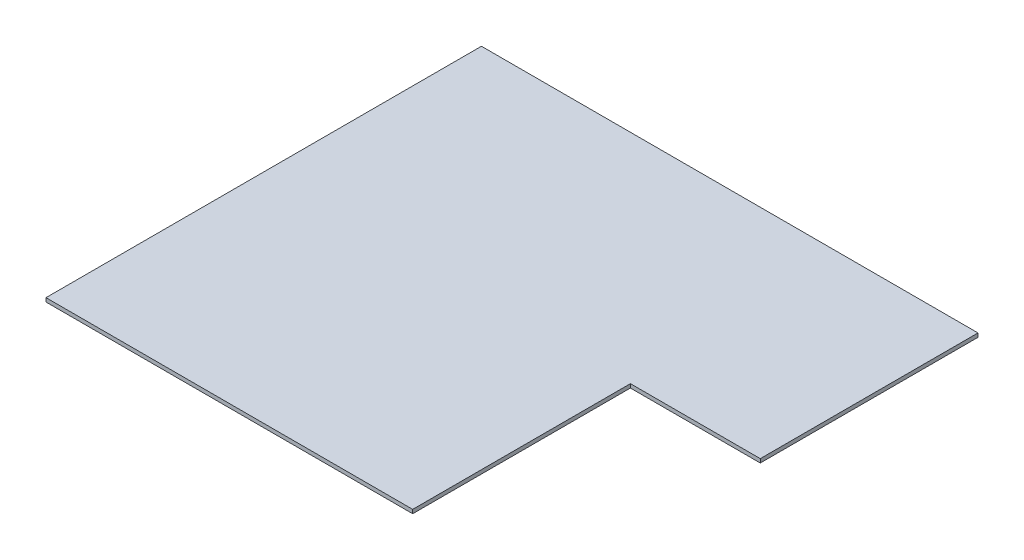
from build123d import *

# Parameters (mm, degrees)
BOSS_EXTRUDE1_DEPTH = 12.7


with BuildPart() as part:
    # Sketch1 → Boss-Extrude1 (new body)
    with BuildSketch(Plane(origin=(0, 0, 0), x_dir=(1, 0, 0), z_dir=(0, 1, 0))):
        Polygon((0, 0), (0, 1447.8), (1651, 1447.8), (1651, 723.9), (1219.2, 723.9), (1219.2, 0), align=None)
    extrude(amount=BOSS_EXTRUDE1_DEPTH)


solid = part.part
